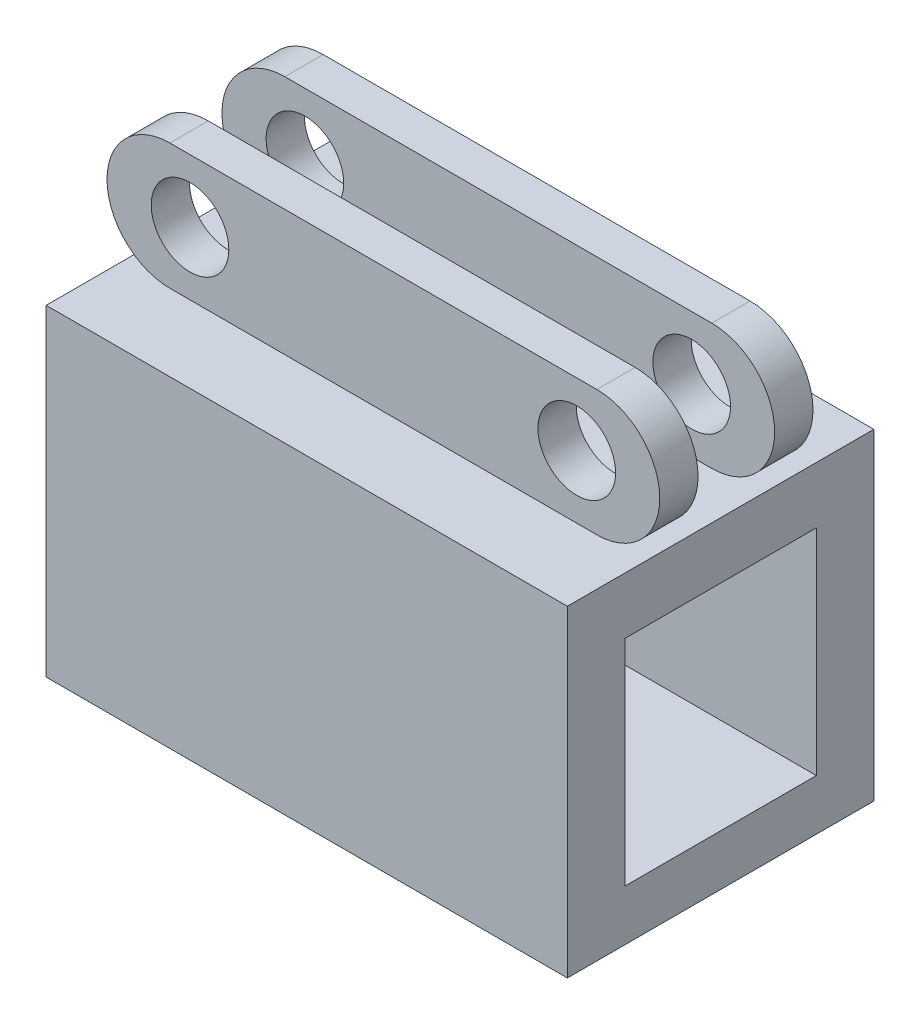
from build123d import *

# Parameters (mm, degrees)
BOSS_EXTRUDE1_DEPTH = 10
SKETCH3_W           = 68.02674373
SKETCH3_H           = 42.022590527
BOSS_EXTRUDE2_DEPTH = 20
SKETCH4_W           = 25
SKETCH4_H           = 28
CUT_EXTRUDE1_DEPTH  = 71.084609616
SKETCH5_R           = 5.067107297
CUT_EXTRUDE2_DEPTH  = 31
SKETCH6_W           = 166.597833244
SKETCH6_H           = 42.962518472
CUT_EXTRUDE3_DEPTH  = 5


with BuildPart() as part:
    # Sketch1 → Boss-Extrude1 (new body, symmetric)
    with BuildSketch(Plane.XY):
        with BuildLine():
            Line((-27.860019642, 8.21121811), (27.860019642, 8.21121811))
            ThreePointArc((27.860019642, 8.21121811), (36.071237751, 0), (27.860019642, -8.21121811))
            Line((27.860019642, -8.21121811), (-27.860019642, -8.21121811))
            ThreePointArc((-27.860019642, -8.21121811), (-36.071237751, 0), (-27.860019642, 8.21121811))
        make_face()
    extrude(amount=BOSS_EXTRUDE1_DEPTH, both=True)

    # Sketch3 → Boss-Extrude2 (add, symmetric)
    with BuildSketch(Plane.XY):
        with Locations((0, -29.222513374)):
            Rectangle(SKETCH3_W, SKETCH3_H)
    extrude(amount=BOSS_EXTRUDE2_DEPTH, both=True)

    # Sketch4 → Cut-Extrude1 (cut, through all)
    with BuildSketch(Plane(origin=(34.013371865, 0, 0), x_dir=(0, 0, -1), z_dir=(1, 0, 0))):
        with Locations((0, -29.598628357)):
            Rectangle(SKETCH4_W, SKETCH4_H)
    extrude(amount=-CUT_EXTRUDE1_DEPTH, mode=Mode.SUBTRACT)

    # Sketch5 → Cut-Extrude2 (cut, through all)
    with BuildSketch(Plane.XY.offset(10)):
        with Locations((-25.241020996, 0)):
            Circle(SKETCH5_R)
        with Locations((25.241020996, 0)):
            Circle(SKETCH5_R)
    extrude(amount=-CUT_EXTRUDE2_DEPTH, mode=Mode.SUBTRACT)

    # Sketch6 → Cut-Extrude3 (cut, symmetric)
    with BuildSketch(Plane.XY):
        with Locations((0.75044069, 13.270041126)):
            Rectangle(SKETCH6_W, SKETCH6_H)
    extrude(amount=CUT_EXTRUDE3_DEPTH, both=True, mode=Mode.SUBTRACT)


solid = part.part
